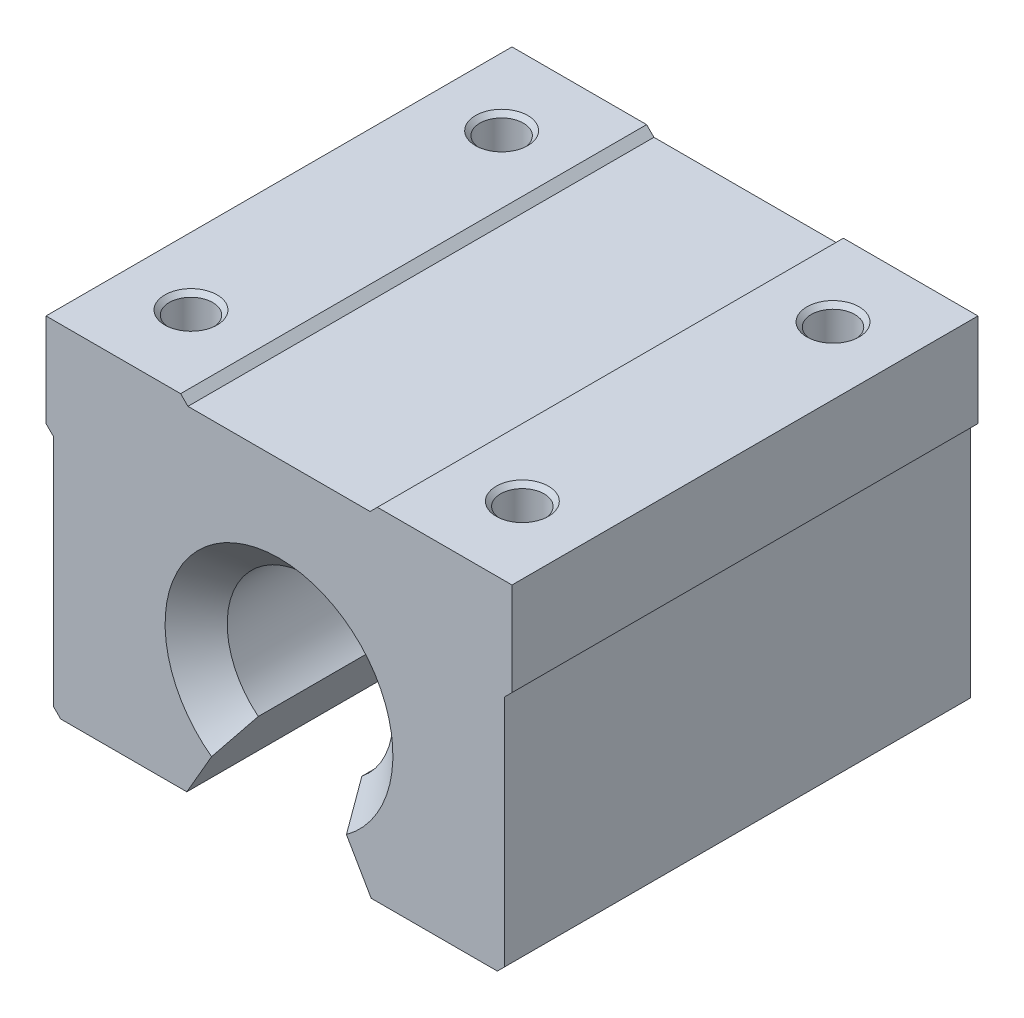
from build123d import *

# Parameters (mm, degrees)
BOSS_EXTRUDE1_DEPTH             = 22.5
M5X0_8_TAPPED_HOLE1_D           = 4.2
M5X0_8_TAPPED_HOLE1_DEPTH       = 12.0000014
M5X0_8_TAPPED_HOLE1_CSINK_D     = 5.05
M5X0_8_TAPPED_HOLE1_CSINK_ANGLE = 90
M5X0_8_TAPPED_HOLE1_TIP         = 1.2618073
CHAMFER1_SIZE                   = 3


with BuildPart() as part:
    # Sketch1 → Boss-Extrude1 (new body, symmetric)
    with BuildSketch(Plane.XY):
        with BuildLine():
            Line((-22.5, 20), (-22.5, 11))
            Line((-22.5, 11), (-21.792893219, 10.292893219))
            Line((-21.792893219, 10.292893219), (-21.792893219, -12.292893219))
            Line((-21.792893219, -12.292893219), (-21.085786438, -13))
            Line((-21.085786438, -13), (-8.900002224, -13))
            Line((-8.900002224, -13), (-5, -6.244997998))
            ThreePointArc((-5, -6.244997998), (0, 8), (5, -6.244997998))
            Line((5, -6.244997998), (8.900002224, -13))
            Line((8.900002224, -13), (21.085786438, -13))
            Line((21.085786438, -13), (21.792893219, -12.292893219))
            Line((21.792893219, -12.292893219), (21.792893219, 10.292893219))
            Line((21.792893219, 10.292893219), (22.5, 11))
            Line((22.5, 11), (22.5, 20))
            Line((22.5, 20), (9.5, 20))
            Line((9.5, 20), (8.792893219, 19.292893219))
            Line((8.792893219, 19.292893219), (-8.792893219, 19.292893219))
            Line((-8.792893219, 19.292893219), (-9.5, 20))
            Line((-9.5, 20), (-22.5, 20))
        make_face()
    extrude(amount=BOSS_EXTRUDE1_DEPTH, both=True)

    # M5x0.8 Tapped Hole1
    with Locations(Plane(origin=(16, 20, 15), x_dir=(0, 0, 1), z_dir=(0, 1, 0))):
        with Locations((0, 0), (-30, 0), (-30, -32), (0, -32)):
            CounterSinkHole(M5X0_8_TAPPED_HOLE1_D / 2, M5X0_8_TAPPED_HOLE1_CSINK_D / 2, depth=M5X0_8_TAPPED_HOLE1_DEPTH, counter_sink_angle=M5X0_8_TAPPED_HOLE1_CSINK_ANGLE)
            with Locations((0, 0, -(M5X0_8_TAPPED_HOLE1_DEPTH + M5X0_8_TAPPED_HOLE1_TIP / 2))):  # 118° drill point
                Cone(0, M5X0_8_TAPPED_HOLE1_D / 2, M5X0_8_TAPPED_HOLE1_TIP, mode=Mode.SUBTRACT)

    # Chamfer1
    chamfer1_edges = [part.edges().sort_by_distance(p)[0] for p in [
        (0, 8, -22.5),
        (0, 8, 22.5),
    ]]
    chamfer(chamfer1_edges, length=CHAMFER1_SIZE)


solid = part.part
